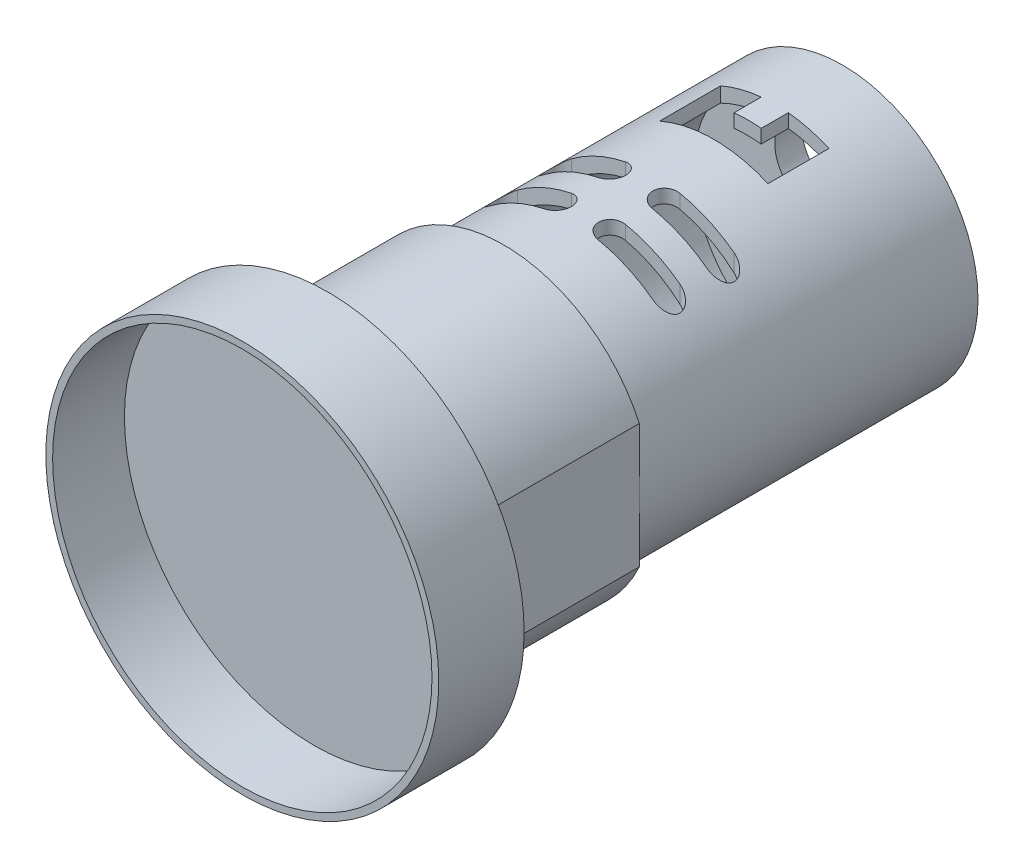
from build123d import *

# Parameters (mm, degrees)
SKETCH1_R               = 10
BOSS_EXTRUDE1_DEPTH     = 38
SKETCH2_R               = 14.5
BOSS_EXTRUDE2_DEPTH     = 1
SKETCH3_R               = 14.5
SKETCH3_R_2             = 14
BOSS_EXTRUDE3_DEPTH     = 5.3
SKETCH4_R               = 11
BOSS_EXTRUDE4_DEPTH     = 13
SKETCH6_R               = 3
CUT_EXTRUDE2_DEPTH      = 9
CUT_EXTRUDE3_DEPTH      = 15.5
CUT_EXTRUDE3_DEPTH_BACK = 15.5
SKETCH8_R               = 9
CUT_EXTRUDE4_DEPTH      = 17
CUT_EXTRUDE4_DEPTH_BACK = 17
SKETCH5_W               = 5
SKETCH5_H               = 40
CUT_EXTRUDE1_DEPTH      = 38


with BuildPart() as part:
    # Sketch1 → Boss-Extrude1 (new body)
    with BuildSketch(Plane.XY):
        Circle(SKETCH1_R)
    extrude(amount=BOSS_EXTRUDE1_DEPTH)

    # Sketch2 → Boss-Extrude2 (add)
    with BuildSketch(Plane.XY.offset(38)):
        Circle(SKETCH2_R)
    extrude(amount=BOSS_EXTRUDE2_DEPTH)

    # Sketch3 → Boss-Extrude3 (add)
    with BuildSketch(Plane.XY.offset(39)):
        Circle(SKETCH3_R)
        Circle(SKETCH3_R_2, mode=Mode.SUBTRACT)
    extrude(amount=BOSS_EXTRUDE3_DEPTH)

    # Sketch4 → Boss-Extrude4 (add)
    with BuildSketch(Plane(origin=(0, 0, 38), x_dir=(-1, 0, 0), z_dir=(0, 0, -1))):
        Circle(SKETCH4_R)
    extrude(amount=BOSS_EXTRUDE4_DEPTH)

    # Sketch6 → Cut-Extrude2 (cut)
    with BuildSketch(Plane(origin=(0, 0, 0), x_dir=(-1, 0, 0), z_dir=(0, 0, -1))):
        with Locations((0, 4.5)):
            Circle(SKETCH6_R)
        with Locations((0, -4.5)):
            Circle(SKETCH6_R)
    extrude(amount=-CUT_EXTRUDE2_DEPTH, mode=Mode.SUBTRACT)

    # Sketch7 → Cut-Extrude3 (cut, two sides)
    with BuildSketch(Plane(origin=(0, 0, 0), x_dir=(1, 0, 0), z_dir=(0, 1, 0))) as cut_extrude3_sk:
        Polygon((-4, -5), (-4, -9.5), (4, -9.5), (4, -5), (1, -5), (1, -7), (-1, -7), (-1, -5), align=None)
        with BuildLine():
            Line((6, -16), (2, -16))
            ThreePointArc((2, -16), (1, -15), (2, -14))
            Line((2, -14), (6, -14))
            ThreePointArc((6, -14), (7, -15), (6, -16))
        make_face()
        with BuildLine():
            Line((-6, -14), (-2, -14))
            ThreePointArc((-2, -14), (-1, -15), (-2, -16))
            Line((-2, -16), (-6, -16))
            ThreePointArc((-6, -16), (-7, -15), (-6, -14))
        make_face()
        with BuildLine():
            Line((6, -18), (2, -18))
            ThreePointArc((2, -18), (1, -19), (2, -20))
            Line((2, -20), (6, -20))
            ThreePointArc((6, -20), (7, -19), (6, -18))
        make_face()
        with BuildLine():
            Line((-6, -20), (-2, -20))
            ThreePointArc((-2, -20), (-1, -19), (-2, -18))
            Line((-2, -18), (-6, -18))
            ThreePointArc((-6, -18), (-7, -19), (-6, -20))
        make_face()
    extrude(amount=CUT_EXTRUDE3_DEPTH, mode=Mode.SUBTRACT)
    extrude(cut_extrude3_sk.sketch, amount=-CUT_EXTRUDE3_DEPTH_BACK, mode=Mode.SUBTRACT)

    # Sketch8 → Cut-Extrude4 (cut, two sides)
    with BuildSketch(Plane.XY.offset(19)) as cut_extrude4_sk:
        Circle(SKETCH8_R)
    extrude(amount=CUT_EXTRUDE4_DEPTH, mode=Mode.SUBTRACT)
    extrude(cut_extrude4_sk.sketch, amount=-CUT_EXTRUDE4_DEPTH_BACK, mode=Mode.SUBTRACT)

    # Sketch5 → Cut-Extrude1 (cut)
    with BuildSketch(Plane(origin=(0, 0, 0), x_dir=(-1, 0, 0), z_dir=(0, 0, -1))):
        with Locations((-12.5, 0)):
            Rectangle(SKETCH5_W, SKETCH5_H)
        with Locations((12.5, 0)):
            Rectangle(SKETCH5_W, SKETCH5_H)
    extrude(amount=-CUT_EXTRUDE1_DEPTH, mode=Mode.SUBTRACT)


solid = part.part
